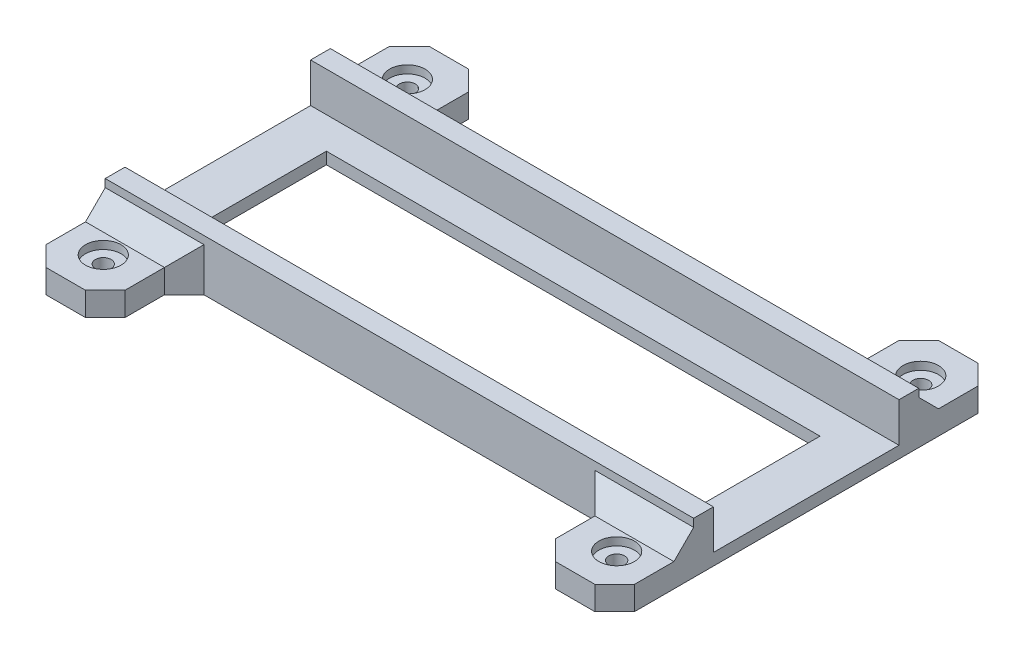
from build123d import *

# Parameters (mm, degrees)
BOSS_EXTRUDE1_DEPTH                        = 10
BOSS_EXTRUDE1_2_DEPTH                      = 10
SKETCH2_W                                  = 149
SKETCH2_H                                  = 57
BOSS_EXTRUDE2_DEPTH                        = 3
SKETCH3_W                                  = 125
SKETCH3_H                                  = 31
CUT_EXTRUDE1_DEPTH                         = 20
SKETCH4_W                                  = 20
SKETCH4_H                                  = 20
BOSS_EXTRUDE3_DEPTH                        = 3
SKETCH5_R                                  = 2
CUT_EXTRUDE2_DEPTH                         = 20
SKETCH6_R                                  = 4.5
CUT_EXTRUDE3_DEPTH                         = 2
MIRROR5_AT_THE_SECOND_PLANE_COPY_1_SKETC_W = 20
MIRROR5_AT_THE_SECOND_PLANE_COPY_1_SKETC_H = 20
MIRROR5_AT_THE_SECOND_PLANE_COPY_1_DEPTH   = 3
MIRROR5_AT_THE_SECOND_PLANE_COPY_2_SKETC_R = 2
MIRROR5_AT_THE_SECOND_PLANE_COPY_2_DEPTH   = 20
MIRROR5_AT_THE_SECOND_PLANE_COPY_3_SKETC_R = 4.5
MIRROR5_AT_THE_SECOND_PLANE_COPY_3_DEPTH   = 2
CHAMFER1_SIZE                              = 5


with BuildPart() as part:
    # Sketch1 → Boss-Extrude1 (new body)
    with BuildSketch(Plane(origin=(0, 0, 0), x_dir=(1, 0, 0), z_dir=(0, 1, 0))):
        Polygon((74.5, 28.5), (-74.5, 28.5), (-74.5, 23.5), (-69.5, 23.5), (69.5, 23.5), (74.5, 23.5), align=None)
    extrude(amount=BOSS_EXTRUDE1_DEPTH)



with BuildPart() as body_2:
    # Sketch1 → Boss-Extrude1 2 (new body)
    with BuildSketch(Plane(origin=(0, 0, 0), x_dir=(1, 0, 0), z_dir=(0, 1, 0))):
        Polygon((-69.5, -23.5), (-74.5, -23.5), (-74.5, -28.5), (74.5, -28.5), (74.5, -23.5), (69.5, -23.5), align=None)
    extrude(amount=BOSS_EXTRUDE1_2_DEPTH)


with BuildPart() as part_1:
    add(part.part)

    add(body_2.part)  # Boss-Extrude2 merges body 2
    # Sketch2 → Boss-Extrude2 (add)
    with BuildSketch(Plane.XZ):
        Rectangle(SKETCH2_W, SKETCH2_H)
    extrude(amount=BOSS_EXTRUDE2_DEPTH)

    # Sketch3 → Cut-Extrude1 (cut)
    with BuildSketch(Plane(origin=(0, 0, 0), x_dir=(1, 0, 0), z_dir=(0, 1, 0))):
        Rectangle(SKETCH3_W, SKETCH3_H)
    extrude(amount=-CUT_EXTRUDE1_DEPTH, mode=Mode.SUBTRACT)

    # Sketch4 → Boss-Extrude3 (add, symmetric)
    with BuildSketch(Plane(origin=(0, 0, 0), x_dir=(1, 0, 0), z_dir=(0, 1, 0))):
        with Locations((-64.5, 38.5)):
            Rectangle(SKETCH4_W, SKETCH4_H)
    boss_extrude3 = extrude(amount=BOSS_EXTRUDE3_DEPTH, both=True)

    # Sketch5 → Cut-Extrude2 (cut)
    with BuildSketch(Plane(origin=(0, 3, 0), x_dir=(1, 0, 0), z_dir=(0, 1, 0))):
        with Locations((-65, 38.5)):
            Circle(SKETCH5_R)
    cut_extrude2 = extrude(amount=-CUT_EXTRUDE2_DEPTH, mode=Mode.SUBTRACT)

    # Sketch6 → Cut-Extrude3 (cut)
    with BuildSketch(Plane(origin=(0, 3, 0), x_dir=(1, 0, 0), z_dir=(0, 1, 0))):
        with Locations((-65, 38.5)):
            Circle(SKETCH6_R)
    cut_extrude3 = extrude(amount=-CUT_EXTRUDE3_DEPTH, mode=Mode.SUBTRACT)

    # Mirror5: Boss-Extrude3, Cut-Extrude2, Cut-Extrude3 across plane
    add(boss_extrude3.mirror(Plane.XY))
    add(cut_extrude2.mirror(Plane.XY), mode=Mode.SUBTRACT)
    add(cut_extrude3.mirror(Plane.XY), mode=Mode.SUBTRACT)

    # Mirror5 at the second plane: Boss-Extrude3, Cut-Extrude3, Cut-Extrude2 across plane
    add(boss_extrude3.mirror(Plane(origin=(0, 0, 0), x_dir=(0, 0, 1), z_dir=(1, 0, 0))))
    add(cut_extrude3.mirror(Plane(origin=(0, 0, 0), x_dir=(0, 0, 1), z_dir=(1, 0, 0))), mode=Mode.SUBTRACT)
    add(cut_extrude2.mirror(Plane(origin=(0, 0, 0), x_dir=(0, 0, 1), z_dir=(1, 0, 0))), mode=Mode.SUBTRACT)

    # Mirror5 at the second plane copy 1 sketc → Mirror5 at the second plane copy 1 (add, symmetric)
    with BuildSketch(Plane(origin=(0, 0, 0), x_dir=(-1, 0, 0), z_dir=(0, 1, 0))):
        with Locations((-64.5, 38.5)):
            Rectangle(MIRROR5_AT_THE_SECOND_PLANE_COPY_1_SKETC_W, MIRROR5_AT_THE_SECOND_PLANE_COPY_1_SKETC_H)
    extrude(amount=MIRROR5_AT_THE_SECOND_PLANE_COPY_1_DEPTH, both=True)

    # Mirror5 at the second plane copy 2 sketc → Mirror5 at the second plane copy 2 (cut)
    with BuildSketch(Plane(origin=(0, 3, 0), x_dir=(-1, 0, 0), z_dir=(0, 1, 0))):
        with Locations((-65, 38.5)):
            Circle(MIRROR5_AT_THE_SECOND_PLANE_COPY_2_SKETC_R)
    extrude(amount=-MIRROR5_AT_THE_SECOND_PLANE_COPY_2_DEPTH, mode=Mode.SUBTRACT)

    # Mirror5 at the second plane copy 3 sketc → Mirror5 at the second plane copy 3 (cut)
    with BuildSketch(Plane(origin=(0, 3, 0), x_dir=(-1, 0, 0), z_dir=(0, 1, 0))):
        with Locations((-65, 38.5)):
            Circle(MIRROR5_AT_THE_SECOND_PLANE_COPY_3_SKETC_R)
    extrude(amount=-MIRROR5_AT_THE_SECOND_PLANE_COPY_3_DEPTH, mode=Mode.SUBTRACT)

    # Chamfer1
    chamfer1_edges = [part_1.edges().sort_by_distance(p)[0] for p in [
        (74.5, 0, 48.5),
        (54.5, 0, 28.5),
        (54.5, 0, 48.5),
        (64.5, 3, 28.5),
        (-74.5, 0, -48.5),
        (-54.5, 0, -28.5),
        (-54.5, 0, -48.5),
        (-64.5, 3, -28.5),
        (74.5, 0, -48.5),
        (54.5, 0, -48.5),
        (54.5, 0, -28.5),
        (64.5, 3, -28.5),
        (-74.5, 0, 48.5),
        (-54.5, 0, 48.5),
        (-54.5, 0, 28.5),
        (-64.5, 3, 28.5),
    ]]
    chamfer(chamfer1_edges, length=CHAMFER1_SIZE)


solid = part_1.part
